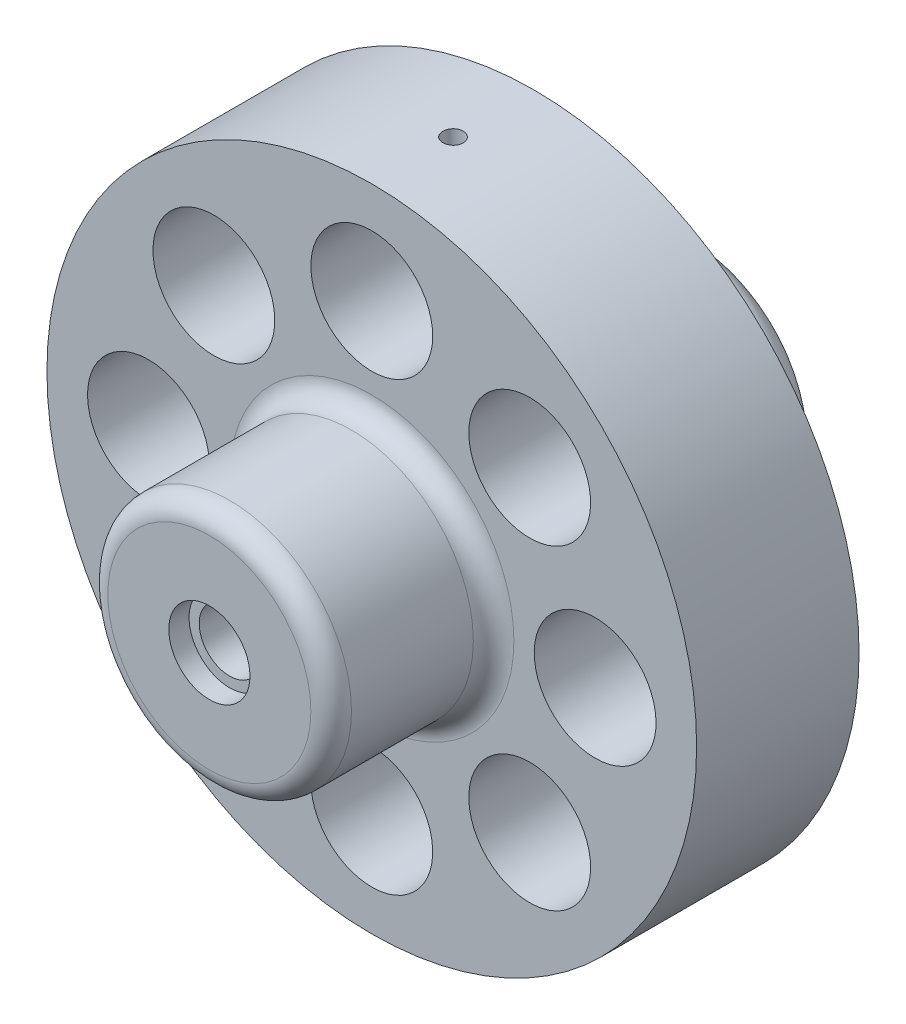
from build123d import *

# Parameters (mm, degrees)
SKETCH1_R                = 203.2
BOSS_EXTRUDE1_DEPTH      = 101.6
BOSS_EXTRUDE2_DEPTH      = 101.6
BOSS_EXTRUDE2_DEPTH_BACK = 203.2
SKETCH3_R                = 76.2
SKETCH4_R                = 19.05
CUT_EXTRUDE2_DEPTH       = 419.907531563
SKETCH5_R                = 38.1
CUT_EXTRUDE3_DEPTH       = 101.6
CIRPATTERN1_COUNT        = 8
FILLET1_R                = 12.7
FILLET2_R                = 12.7
CUT_EXTRUDE4_REACH       = 499.736
SKETCH6_R                = 6.35
CUT_EXTRUDE5_REACH       = 499.736
SKETCH7_R                = 6.35
SKETCH8_R                = 25.4
CUT_EXTRUDE6_DEPTH       = 12.7
CUT_EXTRUDE7_START       = -12.7
SKETCH9_R                = 25.4
CUT_EXTRUDE7_DEPTH       = 12.7


with BuildPart() as part:
    # Sketch1 → Boss-Extrude1 (new body)
    with BuildSketch(Plane.XY):
        Circle(SKETCH1_R)
    extrude(amount=BOSS_EXTRUDE1_DEPTH)

    # Sketch3 → Boss-Extrude2 (add, two sides: drawn at the far end of the back side and taken through both)
    with BuildSketch(Plane.XY.offset(101.6).offset(-BOSS_EXTRUDE2_DEPTH_BACK)):
        Circle(SKETCH3_R)
    extrude(amount=BOSS_EXTRUDE2_DEPTH + BOSS_EXTRUDE2_DEPTH_BACK)

    # Sketch4 → Cut-Extrude2 (cut, through all)
    with BuildSketch(Plane.XY.offset(203.2)):
        Circle(SKETCH4_R)
    extrude(amount=-CUT_EXTRUDE2_DEPTH, mode=Mode.SUBTRACT)

    # Sketch5 → Cut-Extrude3 (cut)
    with BuildSketch(Plane.XY.offset(101.6)):
        with Locations((0, 139.7)):
            Circle(SKETCH5_R)
    cut_extrude3 = extrude(amount=-CUT_EXTRUDE3_DEPTH, mode=Mode.SUBTRACT)

    # CirPattern1: Cut-Extrude3 ×8 about axis
    cirpattern1_axis = Axis((0, 0, -101.6), (0, 0, 1))
    for i in range(1, CIRPATTERN1_COUNT):
        add(cut_extrude3.rotate(cirpattern1_axis, i * 360 / CIRPATTERN1_COUNT), mode=Mode.SUBTRACT)

    # Fillet1
    fillet1_edges = [part.edges().sort_by_distance(p)[0] for p in [
        (-76.2, 0, 101.6),
    ]]
    fillet(fillet1_edges, radius=FILLET1_R)

    # Fillet2
    fillet2_edges = [part.edges().sort_by_distance(p)[0] for p in [
        (-76.2, 0, -101.6),
        (-76.2, 0, 0),
        (-76.2, 0, 203.2),
    ]]
    fillet(fillet2_edges, radius=FILLET2_R)

    # Sketch6 → Cut-Extrude4 (cut, up to next)
    with BuildSketch(Plane(origin=(0, 203.2, 0), x_dir=(-1, 0, 0), z_dir=(0, 1, 0)), mode=Mode.PRIVATE) as cut_extrude4_sk1:
        with Locations((0, 50.8)):
            Circle(SKETCH6_R)
    cut_extrude4_tool1 = extrude(cut_extrude4_sk1.sketch, amount=-CUT_EXTRUDE4_REACH, mode=Mode.PRIVATE) & part.part
    add(cut_extrude4_tool1.solids().sort_by_distance((0, 203.2, 50.8))[0], mode=Mode.SUBTRACT)

    # Sketch7 → Cut-Extrude5 (cut, up to next)
    with BuildSketch(Plane.XZ.offset(203.2), mode=Mode.PRIVATE) as cut_extrude5_sk1:
        with Locations((0, 50.8)):
            Circle(SKETCH7_R)
    cut_extrude5_tool1 = extrude(cut_extrude5_sk1.sketch, amount=-CUT_EXTRUDE5_REACH, mode=Mode.PRIVATE) & part.part
    add(cut_extrude5_tool1.solids().sort_by_distance((0, -203.2, 50.8))[0], mode=Mode.SUBTRACT)

    # Sketch8 → Cut-Extrude6 (cut)
    with BuildSketch(Plane.XY.offset(203.2)):
        Circle(SKETCH8_R)
    extrude(amount=-CUT_EXTRUDE6_DEPTH, mode=Mode.SUBTRACT)

    # Sketch9 → Cut-Extrude7 (cut)
    with BuildSketch(Plane(origin=(0, 0, -101.6), x_dir=(-1, 0, 0), z_dir=(0, 0, -1)).offset(CUT_EXTRUDE7_START)):
        Circle(SKETCH9_R)
    extrude(amount=CUT_EXTRUDE7_DEPTH, mode=Mode.SUBTRACT)


solid = part.part
